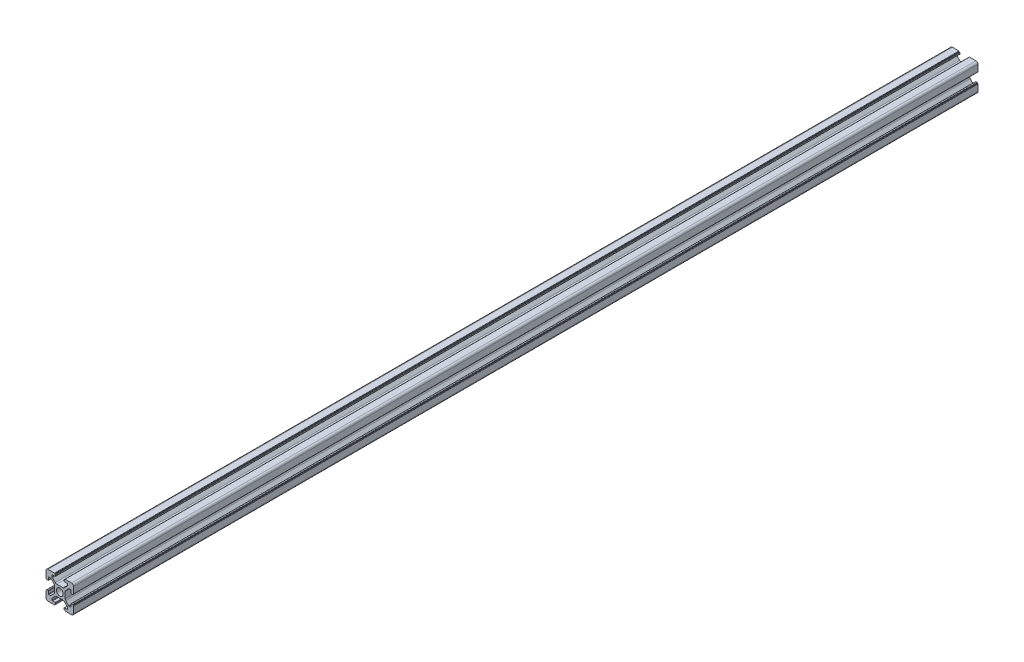
from build123d import *

# Parameters (mm, degrees)
SKETCH_1_R         = 2.5
EXTRUDE_1_DEPTH    = 1220
SKETCH1_R          = 16.771487081
CUT_EXTRUDE1_DEPTH = 565


with BuildPart() as part:
    # 草图1 → 凸台-拉伸1 (new body)
    with BuildSketch(Plane.XY):
        with BuildLine():
            Line((-8.502261885, -10.002261885), (-3.85, -10.002261885))
            ThreePointArc((-3.85, -10.002261885), (-3.673223305, -9.929038581), (-3.6, -9.752261885))
            Line((-3.6, -9.752261885), (-3.6, -9.502261885))
            Line((-3.6, -9.502261885), (-3.35, -9.502261885))
            ThreePointArc((-3.35, -9.502261885), (-3.173223305, -9.429038581), (-3.1, -9.252261885))
            Line((-3.1, -9.252261885), (-3.1, -8.45))
            ThreePointArc((-3.1, -8.45), (-3.173223305, -8.273223305), (-3.35, -8.2))
            Line((-3.35, -8.2), (-5.25, -8.2))
            ThreePointArc((-5.25, -8.2), (-5.426776695, -8.126776695), (-5.5, -7.95))
            Line((-5.5, -7.95), (-5.5, -6.664213562))
            ThreePointArc((-5.5, -6.664213562), (-5.480969883, -6.568542704), (-5.426776695, -6.487436867))
            Line((-5.426776695, -6.487436867), (-3.278679656, -4.339339828))
            ThreePointArc((-3.278679656, -4.339339828), (-2.792044633, -4.014180701), (-2.218019485, -3.9))
            Line((-2.218019485, -3.9), (2.218019485, -3.9))
            ThreePointArc((2.218019485, -3.9), (2.792044633, -4.014180701), (3.278679656, -4.339339828))
            Line((3.278679656, -4.339339828), (5.426776695, -6.487436867))
            ThreePointArc((5.426776695, -6.487436867), (5.480969883, -6.568542704), (5.5, -6.664213562))
            Line((5.5, -6.664213562), (5.5, -7.95))
            ThreePointArc((5.5, -7.95), (5.426776695, -8.126776695), (5.25, -8.2))
            Line((5.25, -8.2), (3.35, -8.2))
            ThreePointArc((3.35, -8.2), (3.173223305, -8.273223305), (3.1, -8.45))
            Line((3.1, -8.45), (3.1, -9.252261885))
            ThreePointArc((3.1, -9.252261885), (3.173223305, -9.429038581), (3.35, -9.502261885))
            Line((3.35, -9.502261885), (3.6, -9.502261885))
            Line((3.6, -9.502261885), (3.6, -9.752261885))
            ThreePointArc((3.6, -9.752261885), (3.673223305, -9.929038581), (3.85, -10.002261885))
            Line((3.85, -10.002261885), (8.502261885, -10.002261885))
            ThreePointArc((8.502261885, -10.002261885), (9.562922057, -9.562922057), (10.002261885, -8.502261885))
            Line((10.002261885, -8.502261885), (10.002261885, -3.85))
            ThreePointArc((10.002261885, -3.85), (9.929038581, -3.673223305), (9.752261885, -3.6))
            Line((9.752261885, -3.6), (9.502261885, -3.6))
            Line((9.502261885, -3.6), (9.502261885, -3.35))
            ThreePointArc((9.502261885, -3.35), (9.429038581, -3.173223305), (9.252261885, -3.1))
            Line((9.252261885, -3.1), (8.45, -3.1))
            ThreePointArc((8.45, -3.1), (8.273223305, -3.173223305), (8.2, -3.35))
            Line((8.2, -3.35), (8.2, -5.25))
            ThreePointArc((8.2, -5.25), (8.126776695, -5.426776695), (7.95, -5.5))
            Line((7.95, -5.5), (6.664213562, -5.5))
            ThreePointArc((6.664213562, -5.5), (6.568542704, -5.480969883), (6.487436867, -5.426776695))
            Line((6.487436867, -5.426776695), (4.339339828, -3.278679656))
            ThreePointArc((4.339339828, -3.278679656), (4.014180701, -2.792044633), (3.9, -2.218019485))
            Line((3.9, -2.218019485), (3.9, 2.218019485))
            ThreePointArc((3.9, 2.218019485), (4.014180701, 2.792044633), (4.339339828, 3.278679656))
            Line((4.339339828, 3.278679656), (6.487436867, 5.426776695))
            ThreePointArc((6.487436867, 5.426776695), (6.568542704, 5.480969883), (6.664213562, 5.5))
            Line((6.664213562, 5.5), (7.95, 5.5))
            ThreePointArc((7.95, 5.5), (8.126776695, 5.426776695), (8.2, 5.25))
            Line((8.2, 5.25), (8.2, 3.35))
            ThreePointArc((8.2, 3.35), (8.273223305, 3.173223305), (8.45, 3.1))
            Line((8.45, 3.1), (9.252261885, 3.1))
            ThreePointArc((9.252261885, 3.1), (9.429038581, 3.173223305), (9.502261885, 3.35))
            Line((9.502261885, 3.35), (9.502261885, 3.6))
            Line((9.502261885, 3.6), (9.752261885, 3.6))
            ThreePointArc((9.752261885, 3.6), (9.929038581, 3.673223305), (10.002261885, 3.85))
            Line((10.002261885, 3.85), (10.002261885, 8.502261885))
            ThreePointArc((10.002261885, 8.502261885), (9.562922057, 9.562922057), (8.502261885, 10.002261885))
            Line((8.502261885, 10.002261885), (3.85, 10.002261885))
            ThreePointArc((3.85, 10.002261885), (3.673223305, 9.929038581), (3.6, 9.752261885))
            Line((3.6, 9.752261885), (3.6, 9.502261885))
            Line((3.6, 9.502261885), (3.35, 9.502261885))
            ThreePointArc((3.35, 9.502261885), (3.173223305, 9.429038581), (3.1, 9.252261885))
            Line((3.1, 9.252261885), (3.1, 8.45))
            ThreePointArc((3.1, 8.45), (3.173223305, 8.273223305), (3.35, 8.2))
            Line((3.35, 8.2), (5.25, 8.2))
            ThreePointArc((5.25, 8.2), (5.426776695, 8.126776695), (5.5, 7.95))
            Line((5.5, 7.95), (5.5, 6.664213562))
            ThreePointArc((5.5, 6.664213562), (5.480969883, 6.568542704), (5.426776695, 6.487436867))
            Line((5.426776695, 6.487436867), (3.278679656, 4.339339828))
            ThreePointArc((3.278679656, 4.339339828), (2.792044633, 4.014180701), (2.218019485, 3.9))
            Line((2.218019485, 3.9), (-2.218019485, 3.9))
            ThreePointArc((-2.218019485, 3.9), (-2.792044633, 4.014180701), (-3.278679656, 4.339339828))
            Line((-3.278679656, 4.339339828), (-5.426776695, 6.487436867))
            ThreePointArc((-5.426776695, 6.487436867), (-5.480969883, 6.568542704), (-5.5, 6.664213562))
            Line((-5.5, 6.664213562), (-5.5, 7.95))
            ThreePointArc((-5.5, 7.95), (-5.426776695, 8.126776695), (-5.25, 8.2))
            Line((-5.25, 8.2), (-3.35, 8.2))
            ThreePointArc((-3.35, 8.2), (-3.173223305, 8.273223305), (-3.1, 8.45))
            Line((-3.1, 8.45), (-3.1, 9.252261885))
            ThreePointArc((-3.1, 9.252261885), (-3.173223305, 9.429038581), (-3.35, 9.502261885))
            Line((-3.35, 9.502261885), (-3.6, 9.502261885))
            Line((-3.6, 9.502261885), (-3.6, 9.752261885))
            ThreePointArc((-3.6, 9.752261885), (-3.673223305, 9.929038581), (-3.85, 10.002261885))
            Line((-3.85, 10.002261885), (-8.502261885, 10.002261885))
            ThreePointArc((-8.502261885, 10.002261885), (-9.562922057, 9.562922057), (-10.002261885, 8.502261885))
            Line((-10.002261885, 8.502261885), (-10.002261885, 3.85))
            ThreePointArc((-10.002261885, 3.85), (-9.929038581, 3.673223305), (-9.752261885, 3.6))
            Line((-9.752261885, 3.6), (-9.502261885, 3.6))
            Line((-9.502261885, 3.6), (-9.502261885, 3.35))
            ThreePointArc((-9.502261885, 3.35), (-9.429038581, 3.173223305), (-9.252261885, 3.1))
            Line((-9.252261885, 3.1), (-8.45, 3.1))
            ThreePointArc((-8.45, 3.1), (-8.273223305, 3.173223305), (-8.2, 3.35))
            Line((-8.2, 3.35), (-8.2, 5.25))
            ThreePointArc((-8.2, 5.25), (-8.126776695, 5.426776695), (-7.95, 5.5))
            Line((-7.95, 5.5), (-6.664213562, 5.5))
            ThreePointArc((-6.664213562, 5.5), (-6.568542704, 5.480969883), (-6.487436867, 5.426776695))
            Line((-6.487436867, 5.426776695), (-4.339339828, 3.278679656))
            ThreePointArc((-4.339339828, 3.278679656), (-4.014180701, 2.792044633), (-3.9, 2.218019485))
            Line((-3.9, 2.218019485), (-3.9, -2.218019485))
            ThreePointArc((-3.9, -2.218019485), (-4.014180701, -2.792044633), (-4.339339828, -3.278679656))
            Line((-4.339339828, -3.278679656), (-6.487436867, -5.426776695))
            ThreePointArc((-6.487436867, -5.426776695), (-6.568542704, -5.480969883), (-6.664213562, -5.5))
            Line((-6.664213562, -5.5), (-7.95, -5.5))
            ThreePointArc((-7.95, -5.5), (-8.126776695, -5.426776695), (-8.2, -5.25))
            Line((-8.2, -5.25), (-8.2, -3.35))
            ThreePointArc((-8.2, -3.35), (-8.273223305, -3.173223305), (-8.45, -3.1))
            Line((-8.45, -3.1), (-9.252261885, -3.1))
            ThreePointArc((-9.252261885, -3.1), (-9.429038581, -3.173223305), (-9.502261885, -3.35))
            Line((-9.502261885, -3.35), (-9.502261885, -3.6))
            Line((-9.502261885, -3.6), (-9.752261885, -3.6))
            ThreePointArc((-9.752261885, -3.6), (-9.929038581, -3.673223305), (-10.002261885, -3.85))
            Line((-10.002261885, -3.85), (-10.002261885, -8.502261885))
            ThreePointArc((-10.002261885, -8.502261885), (-9.562922057, -9.562922057), (-8.502261885, -10.002261885))
        make_face()
        Circle(SKETCH_1_R, mode=Mode.SUBTRACT)
    extrude(amount=EXTRUDE_1_DEPTH)

    # Sketch1 → Cut-Extrude1 (cut, through all)
    with BuildSketch(Plane.XY.offset(564)):
        Circle(SKETCH1_R)
    extrude(amount=-CUT_EXTRUDE1_DEPTH, mode=Mode.SUBTRACT)


solid = part.part
